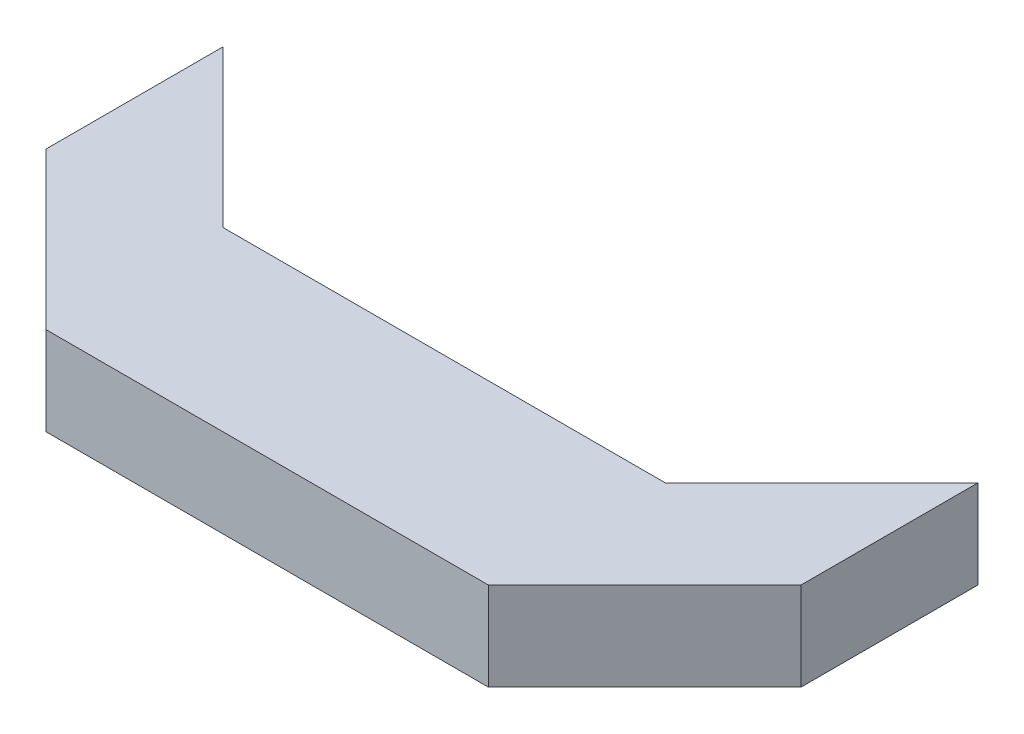
from build123d import *

# Parameters (mm, degrees)
BOSS_EXTRUDE2_DEPTH = 20


with BuildPart() as part:
    # Sketch2 → Boss-Extrude2 (new body)
    with BuildSketch(Plane(origin=(0, 0, 0), x_dir=(1, 0, 0), z_dir=(0, 1, 0))):
        Polygon((50, 20), (85.355339059, 55.355339059), (85.355339059, 15.355339059), (50, -20), (-50, -20), (-85.355339059, 15.355339059), (-85.355339059, 55.355339059), (-50, 20), align=None)
    extrude(amount=BOSS_EXTRUDE2_DEPTH)


solid = part.part
